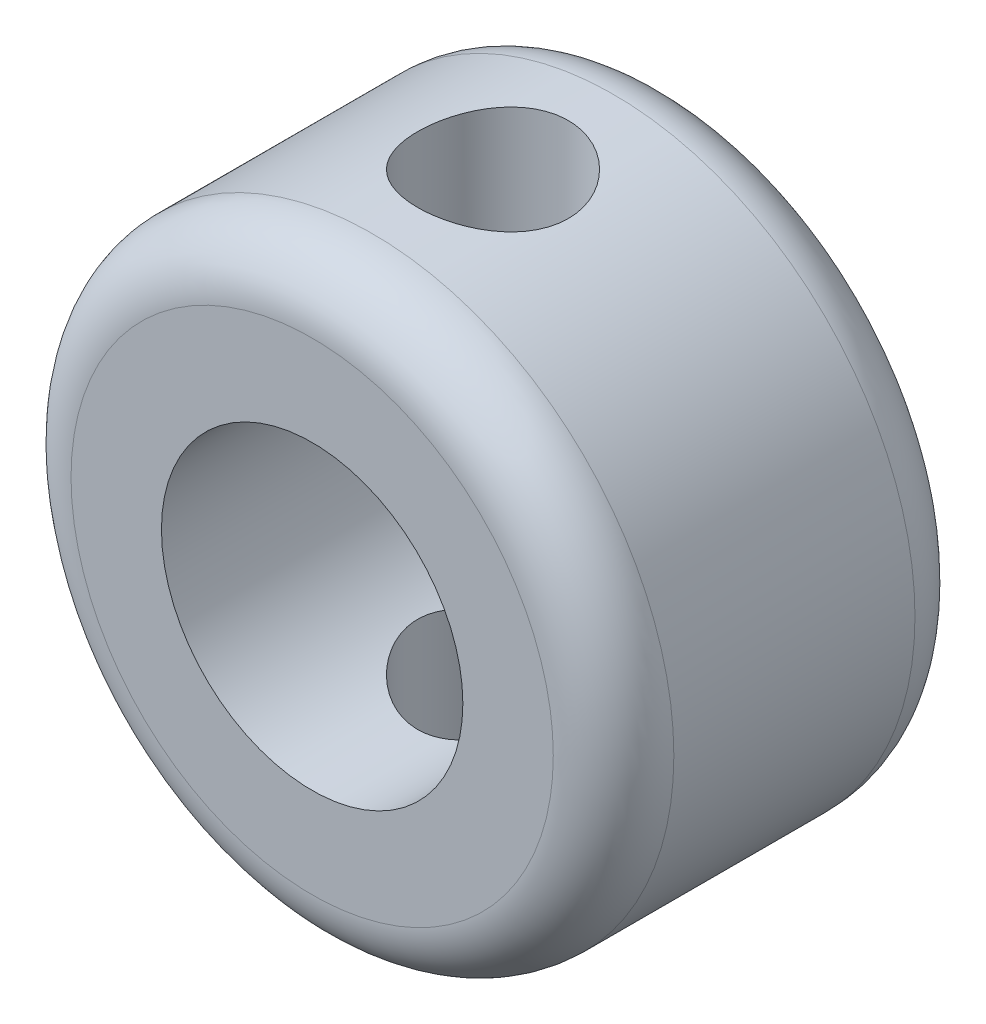
from build123d import *

# Parameters (mm, degrees)
SKETCH1_R               = 5
BOSS_EXTRUDE1_DEPTH     = 6
FILLET3_R               = 1
SKETCH2_R               = 2.5
CUT_EXTRUDE1_DEPTH      = 1
CUT_EXTRUDE1_DEPTH_BACK = 7
SKETCH3_R               = 1.25
CUT_EXTRUDE2_DEPTH      = 6.0000001
CUT_EXTRUDE2_DEPTH_BACK = 6


with BuildPart() as part:
    # Sketch1 → Boss-Extrude1 (new body)
    with BuildSketch(Plane.XY):
        Circle(SKETCH1_R)
    extrude(amount=BOSS_EXTRUDE1_DEPTH)

    # Fillet3
    fillet3_edges = [part.edges().sort_by_distance(p)[0] for p in [
        (-5, 0, 0),
        (-5, 0, 6),
    ]]
    fillet(fillet3_edges, radius=FILLET3_R)

    # Sketch2 → Cut-Extrude1 (cut, two sides)
    with BuildSketch(Plane.XY.offset(6)) as cut_extrude1_sk:
        Circle(SKETCH2_R)
    extrude(amount=CUT_EXTRUDE1_DEPTH, mode=Mode.SUBTRACT)
    extrude(cut_extrude1_sk.sketch, amount=-CUT_EXTRUDE1_DEPTH_BACK, mode=Mode.SUBTRACT)

    # Sketch3 → Cut-Extrude2 (cut, two sides)
    with BuildSketch(Plane(origin=(0, 0, 0), x_dir=(1, 0, 0), z_dir=(0, 1, 0))) as cut_extrude2_sk:
        with Locations((0, -3)):
            Circle(SKETCH3_R)
    extrude(amount=CUT_EXTRUDE2_DEPTH, mode=Mode.SUBTRACT)
    extrude(cut_extrude2_sk.sketch, amount=-CUT_EXTRUDE2_DEPTH_BACK, mode=Mode.SUBTRACT)


solid = part.part
